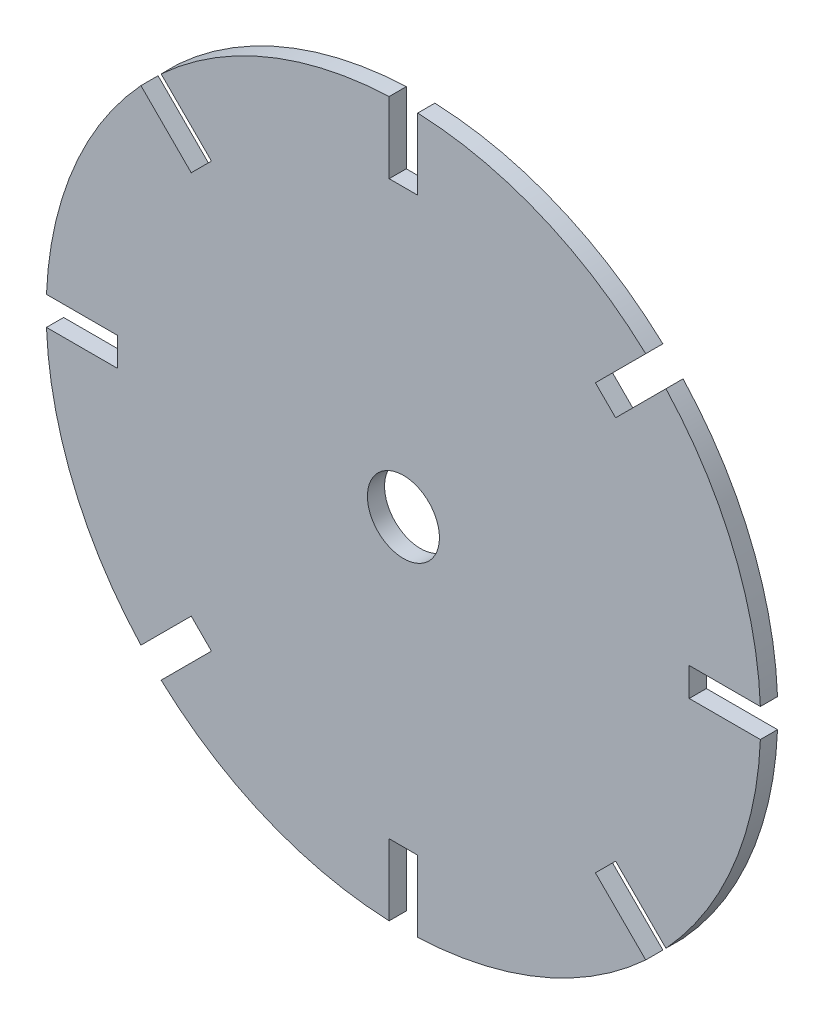
from build123d import *

# Parameters (mm, degrees)
ESQUISSE1_R                  = 125
ESQUISSE1_R_2                = 12.6
BOSS_EXTRU_1_DEPTH           = 6
ESQUISSE2_W                  = 10
ESQUISSE2_H                  = 25
ENL_V_MAT_EXTRU_1_DEPTH      = 7
R_P_TITION_CIRCULAIRE1_COUNT = 8


with BuildPart() as part:
    # Esquisse1 → Boss.-Extru.1 (new body)
    with BuildSketch(Plane.XY):
        Circle(ESQUISSE1_R)
        Circle(ESQUISSE1_R_2, mode=Mode.SUBTRACT)
    extrude(amount=BOSS_EXTRU_1_DEPTH)

    # Esquisse2 → Enlèv. mat.-Extru.1 (cut, through all)
    with BuildSketch(Plane(origin=(0, 0, 0), x_dir=(-1, 0, 0), z_dir=(0, 0, -1))):
        with Locations((0, 112.5)):
            Rectangle(ESQUISSE2_W, ESQUISSE2_H)
    enl_v_mat_extru_1 = extrude(amount=-ENL_V_MAT_EXTRU_1_DEPTH, mode=Mode.SUBTRACT)

    # Répétition circulaire1: Enlèv. mat.-Extru.1 ×8 about axis
    r_p_tition_circulaire1_axis = Axis((0, 0, 0), (0, 0, 1))
    for i in range(1, R_P_TITION_CIRCULAIRE1_COUNT):
        add(enl_v_mat_extru_1.rotate(r_p_tition_circulaire1_axis, i * 360 / R_P_TITION_CIRCULAIRE1_COUNT), mode=Mode.SUBTRACT)


solid = part.part
